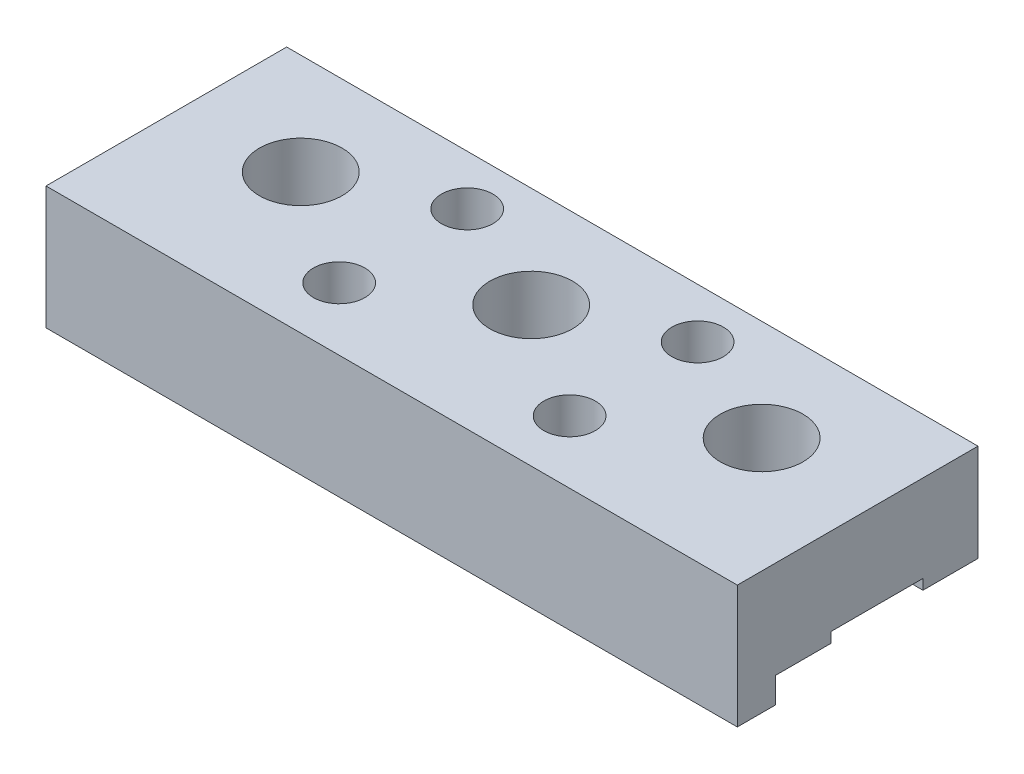
from build123d import *

# Parameters (mm, degrees)
SKETCH1_W                   = 68.58
SKETCH1_H                   = 22.86
EXTRUDE1_DEPTH              = 9.652
SKETCH4_W                   = 68.58
SKETCH4_H                   = 3.81
EXTRUDE3_DEPTH              = 12.192
F_5_16_CLEARANCE_HOLE1_D    = 8.2042
SKETCH3_W                   = 68.58
SKETCH3_H                   = 9.144
EXTRUDE2_DEPTH              = 1.016
SKETCH6_W                   = 68.58
SKETCH6_H                   = 1.3462
CUT_EXTRUDE2_DEPTH          = 10.652
F_1_4_20_TAPPED_HOLE1_D     = 5.1054
F_1_4_20_TAPPED_HOLE1_DEPTH = 19.05
F_1_4_20_TAPPED_HOLE1_TIP   = 1.533816902


with BuildPart() as part:
    # Sketch1 → Extrude1 (new body)
    with BuildSketch(Plane(origin=(0, 0, 0), x_dir=(1, 0, 0), z_dir=(0, 1, 0))):
        Rectangle(SKETCH1_W, SKETCH1_H)
    extrude(amount=EXTRUDE1_DEPTH)

    # Sketch4 → Extrude3 (add)
    with BuildSketch(Plane(origin=(0, 9.652, 0), x_dir=(1, 0, 0), z_dir=(0, 1, 0))):
        with Locations((0, -11.8872)):
            Rectangle(SKETCH4_W, SKETCH4_H)
    extrude(amount=-EXTRUDE3_DEPTH)

    # 5/16 Clearance Hole1 (through all)
    with Locations(Plane(origin=(-22.86, 0, -0.0508), x_dir=(0, 0, -1), z_dir=(0, -1, 0))):
        with Locations((0, 0), (0, 45.72), (0, 22.86)):
            Hole(F_5_16_CLEARANCE_HOLE1_D / 2)

    # Sketch3 → Extrude2 (cut)
    with BuildSketch(Plane.XZ):
        with Locations((0, -0.0508)):
            Rectangle(SKETCH3_W, SKETCH3_H)
    extrude(amount=-EXTRUDE2_DEPTH, mode=Mode.SUBTRACT)

    # Sketch6 → Cut-Extrude2 (cut, through all)
    with BuildSketch(Plane.XZ):
        with Locations((0, -10.7569)):
            Rectangle(SKETCH6_W, SKETCH6_H)
    extrude(amount=-CUT_EXTRUDE2_DEPTH, mode=Mode.SUBTRACT)

    # 1/4-20 Tapped Hole1
    with Locations(Plane(origin=(0, 9.652, 0), x_dir=(-1, 0, 0), z_dir=(0, 1, 0))):
        with Locations((11.43, -5.1308), (11.43, 7.5692), (-11.43, 7.5692), (-11.43, -5.1308)):
            Hole(F_1_4_20_TAPPED_HOLE1_D / 2, depth=F_1_4_20_TAPPED_HOLE1_DEPTH)
            with Locations((0, 0, -(F_1_4_20_TAPPED_HOLE1_DEPTH + F_1_4_20_TAPPED_HOLE1_TIP / 2))):  # 118° drill point
                Cone(0, F_1_4_20_TAPPED_HOLE1_D / 2, F_1_4_20_TAPPED_HOLE1_TIP, mode=Mode.SUBTRACT)


solid = part.part
